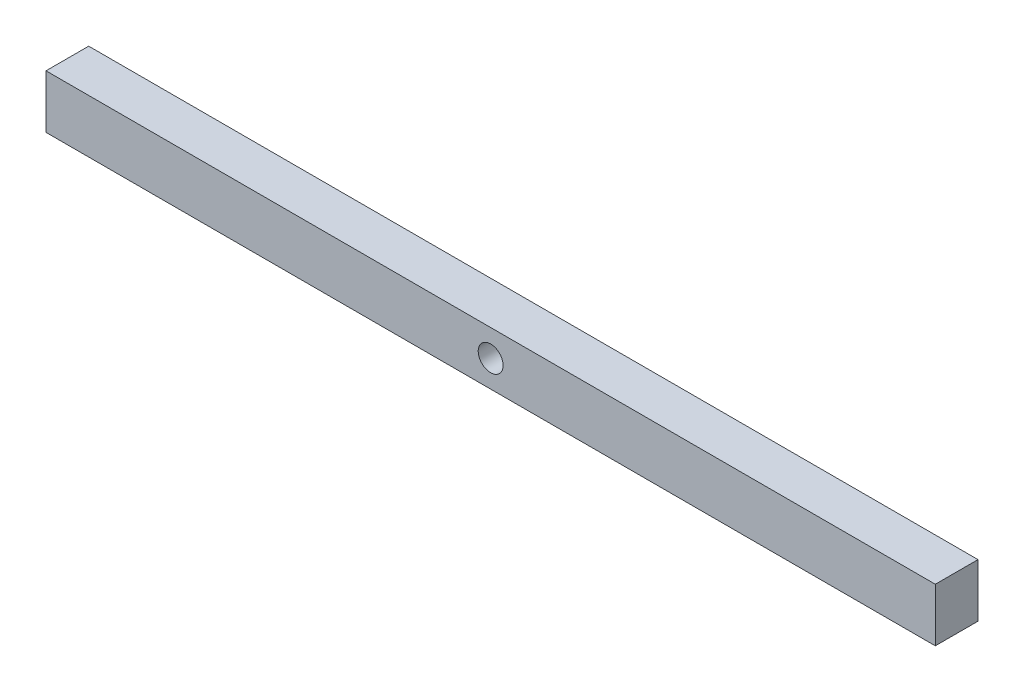
from build123d import *

# Parameters (mm, degrees)
SKETCH1_W           = 127
SKETCH1_H           = 7.62
SKETCH1_R           = 1.778
BOSS_EXTRUDE1_DEPTH = 6.096


with BuildPart() as part:
    # Sketch1 → Boss-Extrude1 (new body)
    with BuildSketch(Plane.XY):
        with Locations((63.5, 3.81)):
            Rectangle(SKETCH1_W, SKETCH1_H)
        with Locations((63.5, 3.81)):
            Circle(SKETCH1_R, mode=Mode.SUBTRACT)
    extrude(amount=BOSS_EXTRUDE1_DEPTH)


solid = part.part
